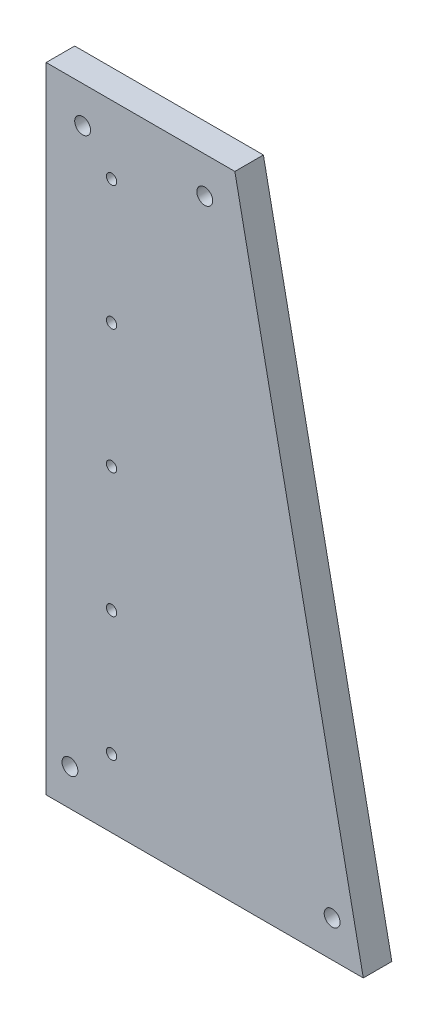
from build123d import *

# Parameters (mm, degrees)
BOSS_EXTRUDE1_DEPTH = 18
SKETCH2_R           = 5
SKETCH2_R_2         = 3.25
CUT_EXTRUDE1_DEPTH  = 19


with BuildPart() as part:
    # Sketch1 → Boss-Extrude1 (new body)
    with BuildSketch(Plane.XY):
        Polygon((-65.310735067, 157.079646018), (15.689264933, -242.920353982), (-65.310735067, -242.920353982), (-184.310735067, -242.920353982), (-184.310735067, 157.079646018), align=None)
    extrude(amount=BOSS_EXTRUDE1_DEPTH)

    # Sketch2 → Cut-Extrude1 (cut, through all)
    with BuildSketch(Plane(origin=(0, 0, 0), x_dir=(-1, 0, 0), z_dir=(0, 0, -1))):
        with Locations((84.310735067, 134.079646018)):
            Circle(SKETCH2_R)
        with Locations((161.310735067, 134.079646018)):
            Circle(SKETCH2_R)
        with Locations((143.060735067, 114.079646018)):
            Circle(SKETCH2_R_2)
        with Locations((143.060735067, 35.579646018)):
            Circle(SKETCH2_R_2)
        with Locations((143.060735067, -42.920353982)):
            Circle(SKETCH2_R_2)
        with Locations((143.060735067, -121.420353982)):
            Circle(SKETCH2_R_2)
        with Locations((143.060735067, -199.920353982)):
            Circle(SKETCH2_R_2)
        with Locations((169.310735067, -219.920353982)):
            Circle(SKETCH2_R)
        with Locations((3.968235067, -219.920353982)):
            Circle(SKETCH2_R)
    extrude(amount=-CUT_EXTRUDE1_DEPTH, mode=Mode.SUBTRACT)


solid = part.part
